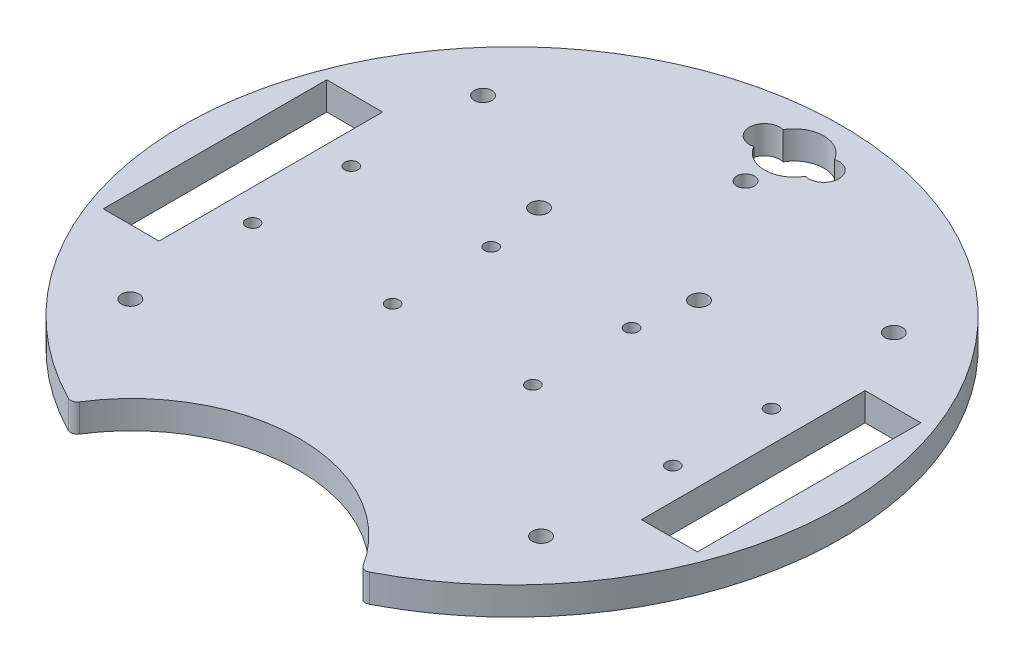
from build123d import *

# Parameters (mm, degrees)
SKETCH1_R           = 2
SKETCH1_W           = 12.7
SKETCH1_H           = 50.8
BOSS_EXTRUDE3_DEPTH = 6.35
SKETCH2_R           = 1.5
CUT_EXTRUDE2_DEPTH  = 10


with BuildPart() as part:
    # Sketch1 → Boss-Extrude3 (new body)
    with BuildSketch(Plane(origin=(0, 0, 0), x_dir=(1, 0, 0), z_dir=(0, 1, 0))):
        with BuildLine():
            ThreePointArc((34.194833578, -66.63583839), (33.11372382, -66.748004461), (32.240681933, -66.10056535))
            ThreePointArc((32.240681933, -66.10056535), (0, -48.302004425), (-32.240681933, -66.10056535))
            ThreePointArc((-32.240681933, -66.10056535), (-33.11372382, -66.748004461), (-34.194833578, -66.63583839))
            ThreePointArc((-34.194833578, -66.63583839), (0, 74.897407173), (34.194833578, -66.63583839))
        make_face()
        with Locations((0, 53.061187965)):
            Circle(SKETCH1_R, mode=Mode.SUBTRACT)
        with Locations((18.178952795, 24.310551096)):
            Circle(SKETCH1_R, mode=Mode.SUBTRACT)
        with Locations((46.663733983, 40.081231883)):
            Circle(SKETCH1_R, mode=Mode.SUBTRACT)
        with Locations((46.663733983, -40.081231883)):
            Circle(SKETCH1_R, mode=Mode.SUBTRACT)
        with Locations((-46.663733983, -40.081231883)):
            Circle(SKETCH1_R, mode=Mode.SUBTRACT)
        with Locations((-18.178952795, 24.310551096)):
            Circle(SKETCH1_R, mode=Mode.SUBTRACT)
        with Locations((-46.663733983, 40.081231883)):
            Circle(SKETCH1_R, mode=Mode.SUBTRACT)
        with Locations((61.164123727, 0)):
            Rectangle(SKETCH1_W, SKETCH1_H, mode=Mode.SUBTRACT)
        with Locations((-61.164123727, 0)):
            Rectangle(SKETCH1_W, SKETCH1_H, mode=Mode.SUBTRACT)
        with BuildLine():
            ThreePointArc((-5.853899988, 60.78531778), (0.003726822, 57.376699875), (5.857575472, 60.791802193))
            ThreePointArc((5.857575472, 60.791802193), (10.16, 64.107698843), (5.857575472, 67.423595493))
            ThreePointArc((5.857575472, 67.423595493), (0.003726822, 70.838697812), (-5.853899988, 67.430079907))
            ThreePointArc((-5.853899988, 67.430079907), (-10.167207264, 64.107698843), (-5.853899988, 60.78531778))
        make_face(mode=Mode.SUBTRACT)
    extrude(amount=BOSS_EXTRUDE3_DEPTH)

    # Sketch2 → Cut-Extrude2 (cut)
    with BuildSketch(Plane(origin=(0, 0, 0), x_dir=(1, 0, 0), z_dir=(0, 1, 0))):
        with Locations((-47.745737366, 11.205)):
            Circle(SKETCH2_R)
        with Locations((-47.745737366, -11.205)):
            Circle(SKETCH2_R)
        with Locations((-15.945737366, 11.205)):
            Circle(SKETCH2_R)
        with Locations((-15.945737366, -11.205)):
            Circle(SKETCH2_R)
        with Locations((15.945737366, -11.205)):
            Circle(SKETCH2_R)
        with Locations((15.945737366, 11.205)):
            Circle(SKETCH2_R)
        with Locations((47.745737366, -11.205)):
            Circle(SKETCH2_R)
        with Locations((47.745737366, 11.205)):
            Circle(SKETCH2_R)
    extrude(amount=CUT_EXTRUDE2_DEPTH, mode=Mode.SUBTRACT)


solid = part.part
